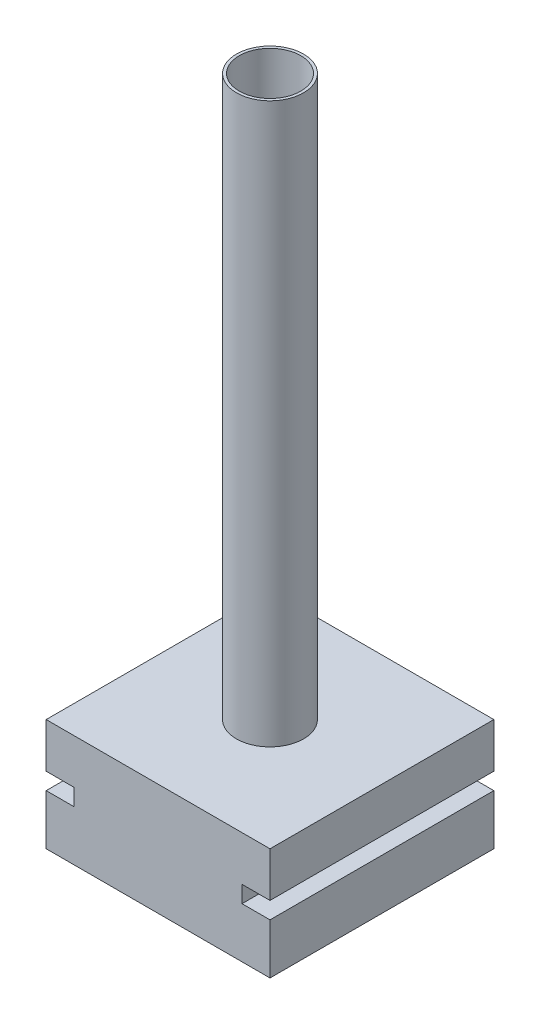
from build123d import *

# Parameters (mm, degrees)
SKETCH1_W           = 400
SKETCH1_H           = 400
BOSS_EXTRUDE1_DEPTH = 200
SKETCH2_R           = 60
SKETCH2_R_2         = 55
BOSS_EXTRUDE2_DEPTH = 1000
SKETCH3_W           = 50
SKETCH3_H           = 30
CUT_EXTRUDE1_DEPTH  = 584


with BuildPart() as part:
    # Sketch1 → Boss-Extrude1 (new body)
    with BuildSketch(Plane(origin=(0, 0, 0), x_dir=(1, 0, 0), z_dir=(0, 1, 0))):
        Rectangle(SKETCH1_W, SKETCH1_H)
    extrude(amount=BOSS_EXTRUDE1_DEPTH)

    # Sketch2 → Boss-Extrude2 (add)
    with BuildSketch(Plane(origin=(0, 200, 0), x_dir=(1, 0, 0), z_dir=(0, 1, 0))):
        Circle(SKETCH2_R)
        Circle(SKETCH2_R_2, mode=Mode.SUBTRACT)
    extrude(amount=BOSS_EXTRUDE2_DEPTH)

    # Sketch3 → Cut-Extrude1 (cut)
    with BuildSketch(Plane(origin=(0, 0, -200), x_dir=(-1, 0, 0), z_dir=(0, 0, -1))):
        with Locations((-175, 105)):
            Rectangle(SKETCH3_W, SKETCH3_H)
        with Locations((175, 105)):
            Rectangle(SKETCH3_W, SKETCH3_H)
    extrude(amount=-CUT_EXTRUDE1_DEPTH, mode=Mode.SUBTRACT)


solid = part.part
